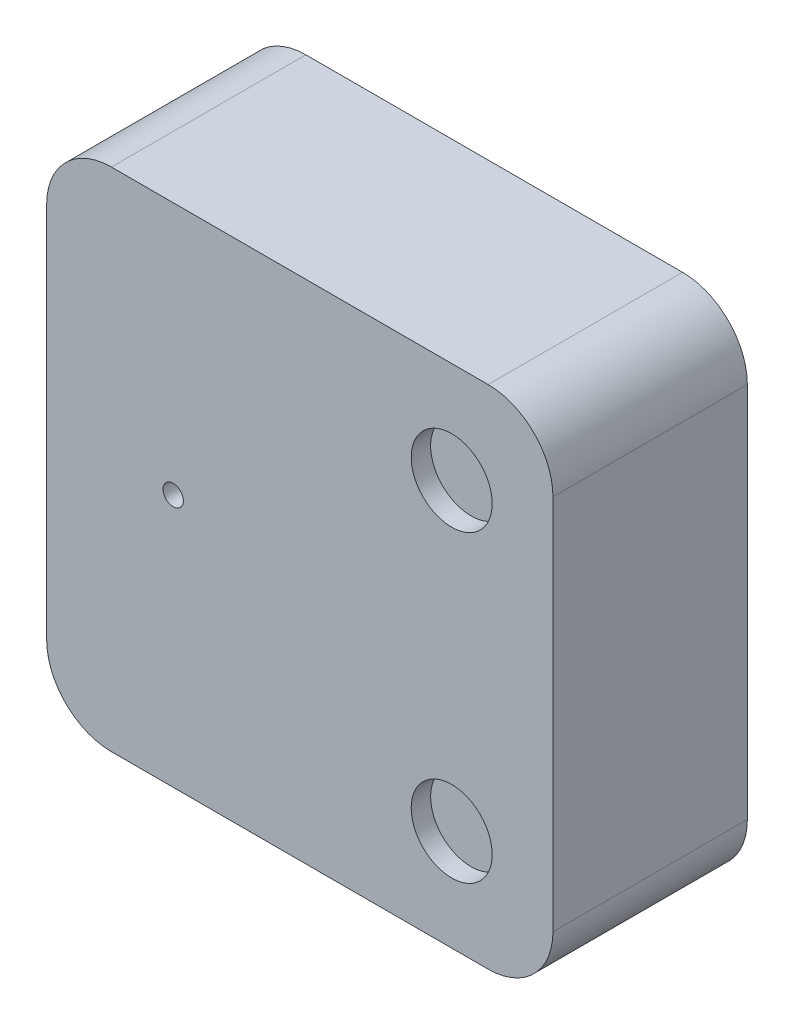
from build123d import *

# Parameters (mm, degrees)
ESQUISSE1_W             = 250
ESQUISSE1_H             = 250
BOSS_EXTRU_1_DEPTH      = 96
CONG_1_R                = 32
ESQUISSE2_R             = 20
ESQUISSE2_R_2           = 5
ENL_V_MAT_EXTRU_1_DEPTH = 9.6


with BuildPart() as part:
    # Esquisse1 → Boss.-Extru.1 (new body)
    with BuildSketch(Plane.XY):
        Rectangle(ESQUISSE1_W, ESQUISSE1_H)
    extrude(amount=BOSS_EXTRU_1_DEPTH)

    # Congé1
    cong_1_edges = [part.edges().sort_by_distance(p)[0] for p in [
        (-125, 125, 48),
        (-125, -125, 48),
        (125, -125, 48),
        (125, 125, 48),
    ]]
    fillet(cong_1_edges, radius=CONG_1_R)

    # Esquisse2 → Enlèv. mat.-Extru.1 (cut)
    with BuildSketch(Plane.XY.offset(96)):
        with Locations((75, 75)):
            Circle(ESQUISSE2_R)
        with Locations((75, -75)):
            Circle(ESQUISSE2_R)
        with Locations((-62.5, 0)):
            Circle(ESQUISSE2_R_2)
    extrude(amount=-ENL_V_MAT_EXTRU_1_DEPTH, mode=Mode.SUBTRACT)


solid = part.part
